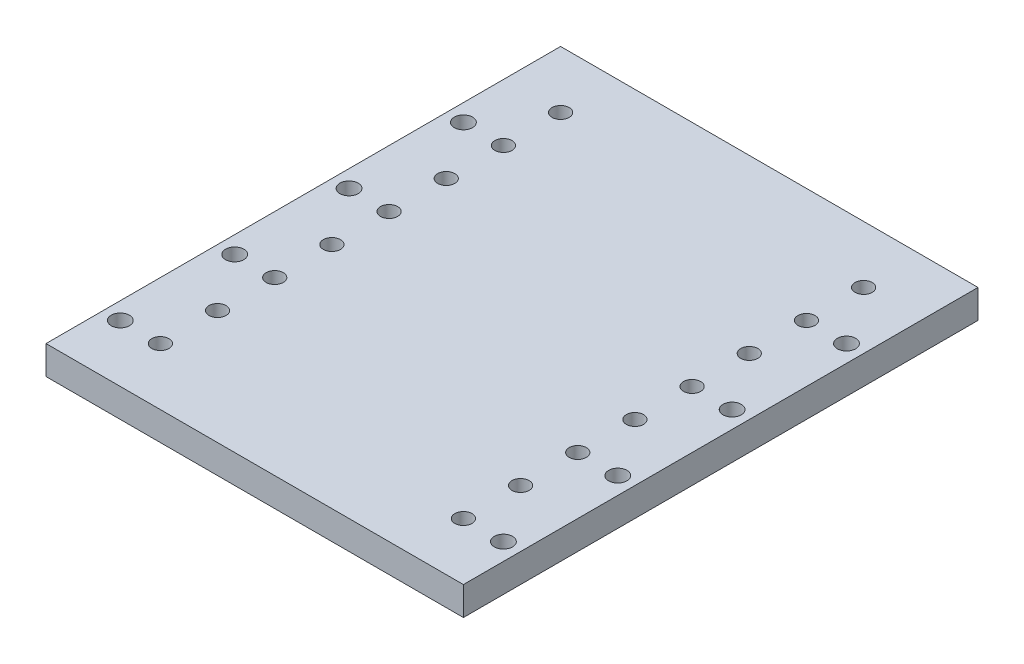
from build123d import *

# Parameters (mm, degrees)
SKETCH_1_W          = 73
SKETCH_1_H          = 90
EXTRUDE_1_DEPTH     = 5
SKETCH_2_R          = 1.6
CUT_EXTRUDE_1_DEPTH = 6
SKETCH_3_R          = 1.5
CUT_EXTRUDE_2_DEPTH = 10


with BuildPart() as part:
    # 草图1 → 凸台-拉伸1 (new body)
    with BuildSketch(Plane(origin=(0, 0, 0), x_dir=(1, 0, 0), z_dir=(0, 1, 0))):
        Rectangle(SKETCH_1_W, SKETCH_1_H)
    extrude(amount=EXTRUDE_1_DEPTH)

    # 草图2 → 切除-拉伸1 (cut, through all)
    with BuildSketch(Plane(origin=(0, 5, 0), x_dir=(1, 0, 0), z_dir=(0, 1, 0))):
        with Locations((-33.5, 25)):
            Circle(SKETCH_2_R)
        with Locations((-33.5, 5)):
            Circle(SKETCH_2_R)
        with Locations((-33.5, -15)):
            Circle(SKETCH_2_R)
        with Locations((-33.5, -35)):
            Circle(SKETCH_2_R)
        with Locations((33.5, -35)):
            Circle(SKETCH_2_R)
        with Locations((33.5, -15)):
            Circle(SKETCH_2_R)
        with Locations((33.5, 5)):
            Circle(SKETCH_2_R)
        with Locations((33.5, 25)):
            Circle(SKETCH_2_R)
    extrude(amount=-CUT_EXTRUDE_1_DEPTH, mode=Mode.SUBTRACT)

    # 草图3 → 切除-拉伸2 (cut)
    with BuildSketch(Plane(origin=(0, 5, 0), x_dir=(1, 0, 0), z_dir=(0, 1, 0))):
        with Locations((26.5, 25)):
            Circle(SKETCH_3_R)
        with Locations((26.5, 15)):
            Circle(SKETCH_3_R)
        with Locations((26.5, 35)):
            Circle(SKETCH_3_R)
        with Locations((26.5, 5)):
            Circle(SKETCH_3_R)
        with Locations((26.5, -5)):
            Circle(SKETCH_3_R)
        with Locations((26.5, -15)):
            Circle(SKETCH_3_R)
        with Locations((26.5, -25)):
            Circle(SKETCH_3_R)
        with Locations((26.5, -35)):
            Circle(SKETCH_3_R)
        with Locations((-26.5, -35)):
            Circle(SKETCH_3_R)
        with Locations((-26.5, -25)):
            Circle(SKETCH_3_R)
        with Locations((-26.5, -15)):
            Circle(SKETCH_3_R)
        with Locations((-26.5, -5)):
            Circle(SKETCH_3_R)
        with Locations((-26.5, 5)):
            Circle(SKETCH_3_R)
        with Locations((-26.5, 15)):
            Circle(SKETCH_3_R)
        with Locations((-26.5, 25)):
            Circle(SKETCH_3_R)
        with Locations((-26.5, 35)):
            Circle(SKETCH_3_R)
    extrude(amount=-CUT_EXTRUDE_2_DEPTH, mode=Mode.SUBTRACT)


solid = part.part
